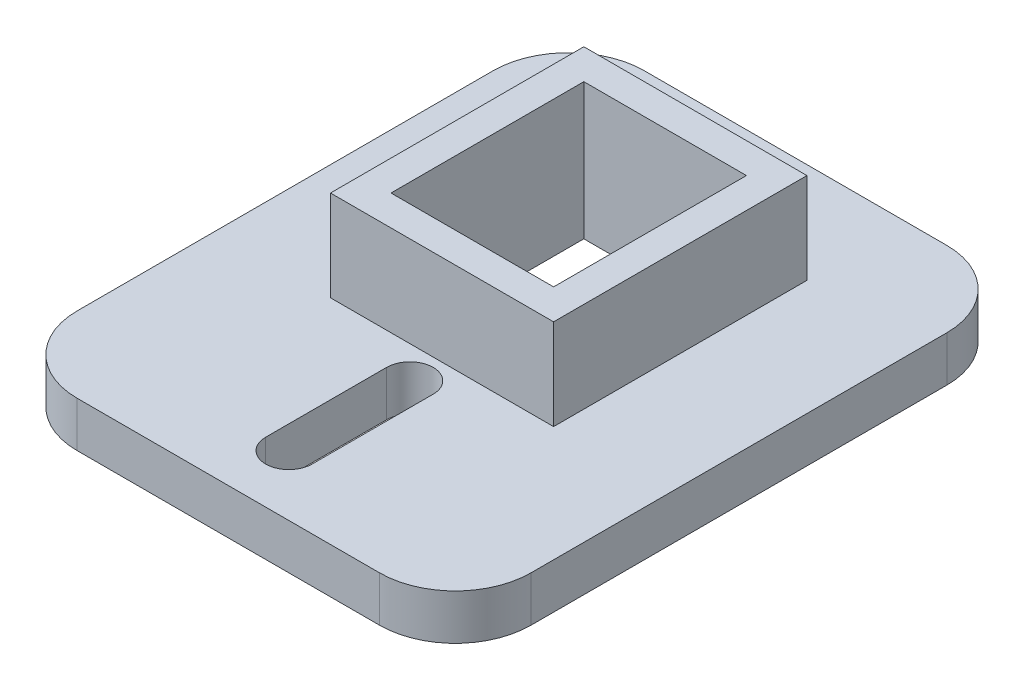
from build123d import *

# Parameters (mm, degrees)
SKETCH1_W           = 30
SKETCH1_H           = 37.5
SKETCH1_W_2         = 10.75
SKETCH1_H_2         = 12.75
BOSS_EXTRUDE1_DEPTH = 3
FILLET1_R           = 5
SKETCH2_W           = 14.75
SKETCH2_H           = 16.75
SKETCH2_W_2         = 10.75
SKETCH2_H_2         = 12.75
BOSS_EXTRUDE2_DEPTH = 6


with BuildPart() as part:
    # Sketch1 → Boss-Extrude1 (new body)
    with BuildSketch(Plane(origin=(0, 0, 0), x_dir=(1, 0, 0), z_dir=(0, 1, 0))):
        with Locations((0, -4.375)):
            Rectangle(SKETCH1_W, SKETCH1_H)
        with BuildLine():
            Line((1.5375, -11.125), (1.5375, -19.125))
            ThreePointArc((1.5375, -19.125), (0, -20.6625), (-1.5375, -19.125))
            Line((-1.5375, -19.125), (-1.5375, -11.125))
            ThreePointArc((-1.5375, -11.125), (0, -9.5875), (1.5375, -11.125))
        make_face(mode=Mode.SUBTRACT)
        with Locations((0, -0.625)):
            Rectangle(SKETCH1_W_2, SKETCH1_H_2, mode=Mode.SUBTRACT)
    extrude(amount=BOSS_EXTRUDE1_DEPTH)

    # Fillet1
    fillet1_edges = [part.edges().sort_by_distance(p)[0] for p in [
        (15, 1.5, 23.125),
        (-15, 1.5, 23.125),
        (-15, 1.5, -14.375),
        (15, 1.5, -14.375),
    ]]
    fillet(fillet1_edges, radius=FILLET1_R)

    # Sketch2 → Boss-Extrude2 (add)
    with BuildSketch(Plane(origin=(0, 3, 0), x_dir=(1, 0, 0), z_dir=(0, 1, 0))):
        with Locations((0, -0.625)):
            Rectangle(SKETCH2_W, SKETCH2_H)
        with Locations((0, -0.625)):
            Rectangle(SKETCH2_W_2, SKETCH2_H_2, mode=Mode.SUBTRACT)
    extrude(amount=BOSS_EXTRUDE2_DEPTH)


solid = part.part
